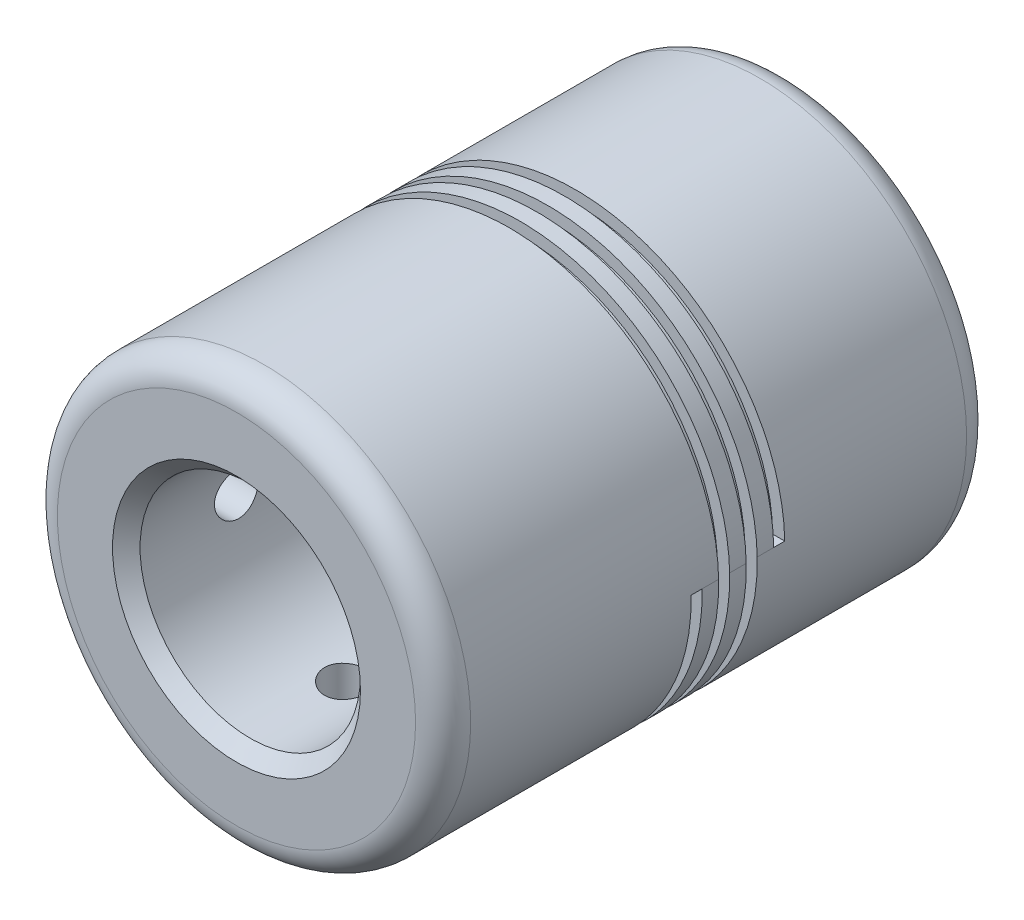
from build123d import *

# Parameters (mm, degrees)
SCHIZZO1_R                    = 7.5
ESTRUSIONE_ESTRUSIONE1_DEPTH  = 20
SCHIZZO2_R                    = 4
TAGLIO_ESTRUSIONE1_DEPTH      = 10
TAGLIO_ESTRUSIONE2_REACH      = 16.577
SCHIZZO3_R                    = 2.6
RACCORDO1_R                   = 1
TAGLIO_ESTRUSIONE3_REACH      = 24.638
TAGLIO_ESTRUSIONE3_END_RADIUS = 7.5
SCHIZZO4_R                    = 0.8
RIPETIZIONECIRCOLARE1_COUNT   = 2
RIPETIZIONECIRCOLARE1_ANGLE   = 90
TAGLIA_SWEEP1_PITCH           = 1
TAGLIA_SWEEP1_HEIGHT          = 3
TAGLIA_SWEEP1_RADIUS          = 7.5
SCHIZZO6_W                    = 0.968384427
SCHIZZO6_H                    = 0.4
SMUSSO1_SIZE                  = 0.5


with BuildPart() as part:
    # Schizzo1 → Estrusione-Estrusione1 (new body)
    with BuildSketch(Plane.XY):
        Circle(SCHIZZO1_R)
    extrude(amount=ESTRUSIONE_ESTRUSIONE1_DEPTH)

    # Schizzo2 → Taglio-Estrusione1 (cut)
    with BuildSketch(Plane.XY.offset(20)):
        Circle(SCHIZZO2_R)
    extrude(amount=-TAGLIO_ESTRUSIONE1_DEPTH, mode=Mode.SUBTRACT)

    # Schizzo3 → Taglio-Estrusione2 (cut, up to next)
    with BuildSketch(Plane.XY.offset(10), mode=Mode.PRIVATE) as taglio_estrusione2_sk1:
        Circle(SCHIZZO3_R)
    taglio_estrusione2_tool1 = extrude(taglio_estrusione2_sk1.sketch, amount=-TAGLIO_ESTRUSIONE2_REACH, mode=Mode.PRIVATE) & part.part
    add(taglio_estrusione2_tool1.solids().sort_by_distance((0, 0, 10))[0], mode=Mode.SUBTRACT)

    # Raccordo1
    raccordo1_edges = [part.edges().sort_by_distance(p)[0] for p in [
        (-7.5, 0, 0),
        (-7.5, 0, 20),
    ]]
    fillet(raccordo1_edges, radius=RACCORDO1_R)

    # Taglio-Estrusione3: up to this cylinder (the profile starts inside it)
    taglio_estrusione3_end = Plane(origin=(0, 0, 10), z_dir=(0, 0, -1)) * Cylinder(TAGLIO_ESTRUSIONE3_END_RADIUS, 77.276, mode=Mode.PRIVATE)
    # Schizzo4 → Taglio-Estrusione3 (cut, up to the surface)
    with BuildSketch(Plane(origin=(0, 0, 0), x_dir=(1, 0, 0), z_dir=(0, 1, 0)), mode=Mode.PRIVATE) as taglio_estrusione3_sk1:
        with Locations(Location((0, -4, 0), (0, 0, 270))):
            Circle(SCHIZZO4_R)
    taglio_estrusione3_tool1 = extrude(taglio_estrusione3_sk1.sketch, amount=-TAGLIO_ESTRUSIONE3_REACH, mode=Mode.PRIVATE) & taglio_estrusione3_end
    # Schizzo4 → Taglio-Estrusione3 (cut, up to the surface)
    with BuildSketch(Plane(origin=(0, 0, 0), x_dir=(1, 0, 0), z_dir=(0, 1, 0)), mode=Mode.PRIVATE) as taglio_estrusione3_sk2:
        with Locations(Location((0, -16, 0), (0, 0, 270))):
            Circle(SCHIZZO4_R)
    taglio_estrusione3_tool2 = extrude(taglio_estrusione3_sk2.sketch, amount=-TAGLIO_ESTRUSIONE3_REACH, mode=Mode.PRIVATE) & taglio_estrusione3_end
    taglio_estrusione3 = taglio_estrusione3_tool1.solids().sort_by_distance((0, 0, 4))[0] + taglio_estrusione3_tool2.solids().sort_by_distance((0, 0, 16))[0]
    add(taglio_estrusione3, mode=Mode.SUBTRACT)

    # RipetizioneCircolare1: Taglio-Estrusione3 ×2 about axis
    ripetizionecircolare1_axis = Axis((0, 0, 19), (0, 0, -1))
    for i in range(1, RIPETIZIONECIRCOLARE1_COUNT):
        add(taglio_estrusione3.rotate(ripetizionecircolare1_axis, i * RIPETIZIONECIRCOLARE1_ANGLE / (RIPETIZIONECIRCOLARE1_COUNT - 1)), mode=Mode.SUBTRACT)

    # Taglia-Sweep1: sweep along a helix
    with BuildLine() as taglia_sweep1_path:
        Helix(TAGLIA_SWEEP1_PITCH, TAGLIA_SWEEP1_HEIGHT, TAGLIA_SWEEP1_RADIUS, center=(0, 0, 8), direction=(0, 0, 1))
    # Schizzo6 → Taglia-Sweep1 (sweep, cut)
    with BuildSketch(Plane(origin=(0, 0, 0), x_dir=(1, 0, 0), z_dir=(0, 1, 0))):
        with Locations((7.548402887, -7.8)):
            Rectangle(SCHIZZO6_W, SCHIZZO6_H)
    sweep(path=taglia_sweep1_path.line, is_frenet=True, mode=Mode.SUBTRACT)

    # Smusso1
    smusso1_edges = [part.edges().sort_by_distance(p)[0] for p in [
        (-2.6, 0, 0),
        (-4, 0, 20),
    ]]
    chamfer(smusso1_edges, length=SMUSSO1_SIZE)


solid = part.part
